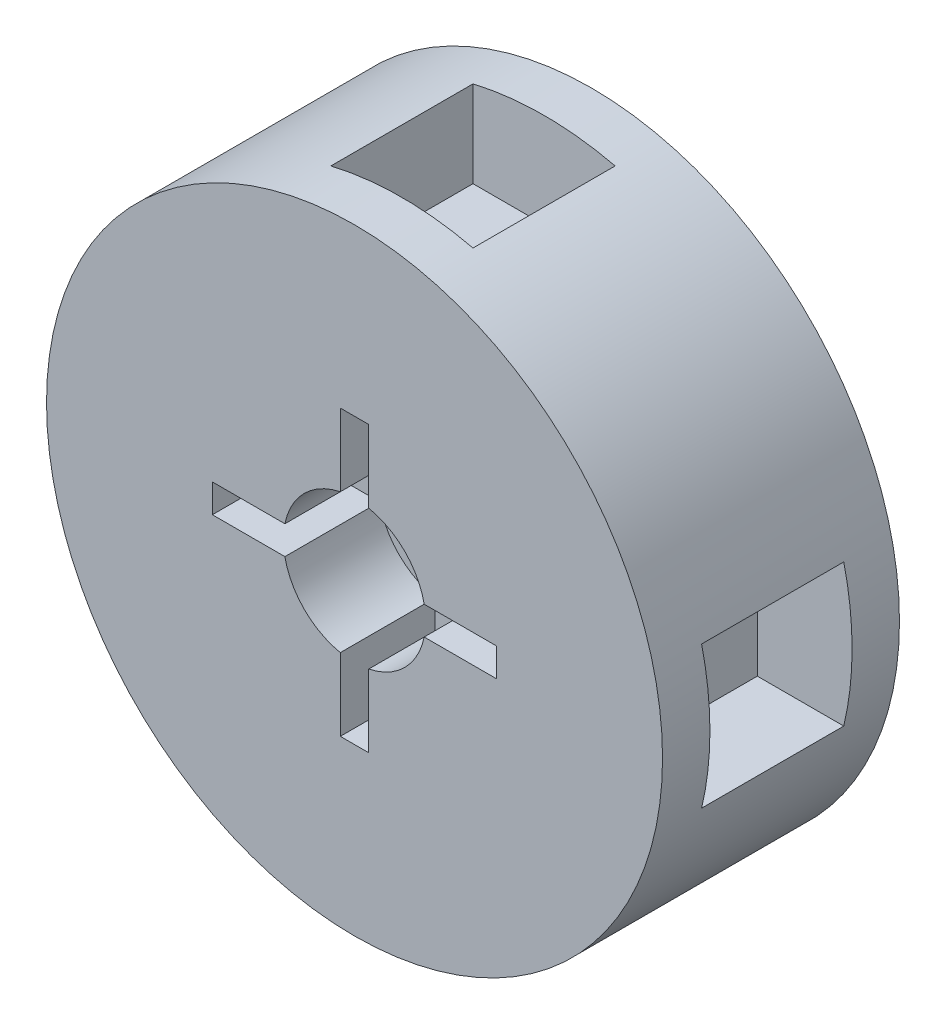
from build123d import *

# Parameters (mm, degrees)
SKETCH1_R           = 32.5
BOSS_EXTRUDE1_DEPTH = 25
SKETCH2_R           = 20
CUT_EXTRUDE1_DEPTH  = 10
SKETCH3_R           = 7.5
SKETCH3_W           = 30
SKETCH3_H           = 3
SKETCH3_W_2         = 3
SKETCH3_H_2         = 30
CUT_EXTRUDE2_DEPTH  = 10
SKETCH4_W           = 15
SKETCH4_H           = 15
CUT_EXTRUDE3_DEPTH  = 10
SKETCH6_W           = 15
SKETCH6_H           = 15
CUT_EXTRUDE4_DEPTH  = 10
SKETCH7_W           = 15
SKETCH7_H           = 15
CUT_EXTRUDE5_DEPTH  = 10
SKETCH8_W           = 15
SKETCH8_H           = 15
CUT_EXTRUDE6_DEPTH  = 10


with BuildPart() as part:
    # Sketch1 → Boss-Extrude1 (new body)
    with BuildSketch(Plane.XY):
        Circle(SKETCH1_R)
    extrude(amount=BOSS_EXTRUDE1_DEPTH)

    # Sketch2 → Cut-Extrude1 (cut)
    with BuildSketch(Plane(origin=(0, 0, 0), x_dir=(-1, 0, 0), z_dir=(0, 0, -1))):
        Circle(SKETCH2_R)
    extrude(amount=-CUT_EXTRUDE1_DEPTH, mode=Mode.SUBTRACT)

    # Sketch3 → Cut-Extrude2 (cut)
    with BuildSketch(Plane.XY.offset(25)):
        Circle(SKETCH3_R)
        Rectangle(SKETCH3_W, SKETCH3_H)
        Rectangle(SKETCH3_W_2, SKETCH3_H_2)
    extrude(amount=-CUT_EXTRUDE2_DEPTH, mode=Mode.SUBTRACT)

    # Sketch4 → Cut-Extrude3 (cut)
    with BuildSketch(Plane(origin=(32.5, 0, 0), x_dir=(0, 0, -1), z_dir=(1, 0, 0))):
        with Locations((-12.5, 0)):
            Rectangle(SKETCH4_W, SKETCH4_H)
    extrude(amount=-CUT_EXTRUDE3_DEPTH, mode=Mode.SUBTRACT)

    # Sketch6 → Cut-Extrude4 (cut)
    with BuildSketch(Plane.ZY.offset(32.5)):
        with Locations((12.5, 0)):
            Rectangle(SKETCH6_W, SKETCH6_H)
    extrude(amount=-CUT_EXTRUDE4_DEPTH, mode=Mode.SUBTRACT)

    # Sketch7 → Cut-Extrude5 (cut)
    with BuildSketch(Plane(origin=(0, 32.5, 0), x_dir=(1, 0, 0), z_dir=(0, 1, 0))):
        with Locations((0, -12.5)):
            Rectangle(SKETCH7_W, SKETCH7_H)
    extrude(amount=-CUT_EXTRUDE5_DEPTH, mode=Mode.SUBTRACT)

    # Sketch8 → Cut-Extrude6 (cut)
    with BuildSketch(Plane(origin=(0, -32.5, 0), x_dir=(-1, 0, 0), z_dir=(0, -1, 0))):
        with Locations((0, -12.5)):
            Rectangle(SKETCH8_W, SKETCH8_H)
    extrude(amount=-CUT_EXTRUDE6_DEPTH, mode=Mode.SUBTRACT)


solid = part.part
